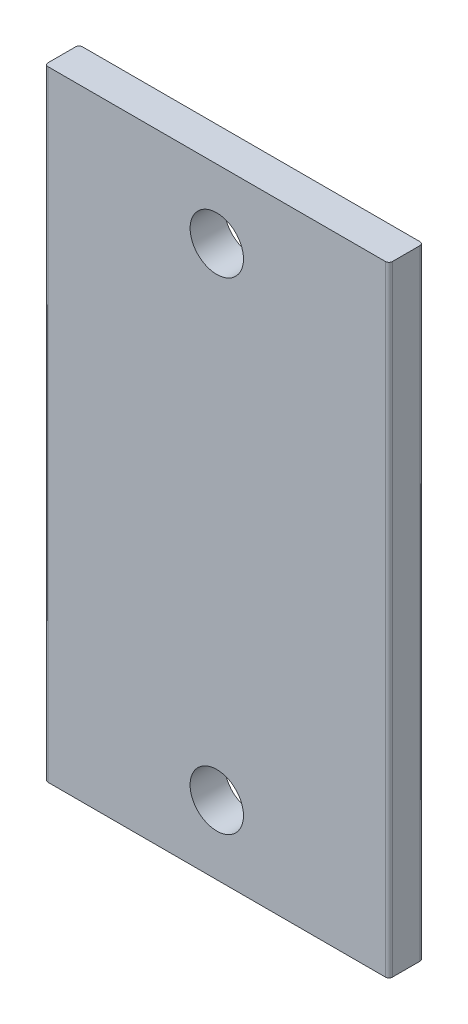
from build123d import *

# Parameters (mm, degrees)
ESQUISSE1_W               = 100
ESQUISSE1_H               = 180
BOSS_EXTRU_1_DEPTH        = 10
M14_CLEARANCE_HOLE1_D     = 15.5
M14_CLEARANCE_HOLE1_DEPTH = 10
FILLET1_R                 = 1


with BuildPart() as part:
    # Esquisse1 → Boss.-Extru.1 (new body)
    with BuildSketch(Plane.XY):
        Rectangle(ESQUISSE1_W, ESQUISSE1_H)
    extrude(amount=BOSS_EXTRU_1_DEPTH)

    # M14 Clearance Hole1
    with Locations(Plane.XY.offset(10)):
        with Locations((0, 70), (0, -70), (60, -70), (60, 70)):
            Hole(M14_CLEARANCE_HOLE1_D / 2, depth=M14_CLEARANCE_HOLE1_DEPTH)

    # Fillet1
    fillet1_edges = [part.edges().sort_by_distance(p)[0] for p in [
        (-50, 0, 10),
        (50, 0, 10),
        (-50, 0, 0),
        (50, 0, 0),
    ]]
    fillet(fillet1_edges, radius=FILLET1_R)


solid = part.part
